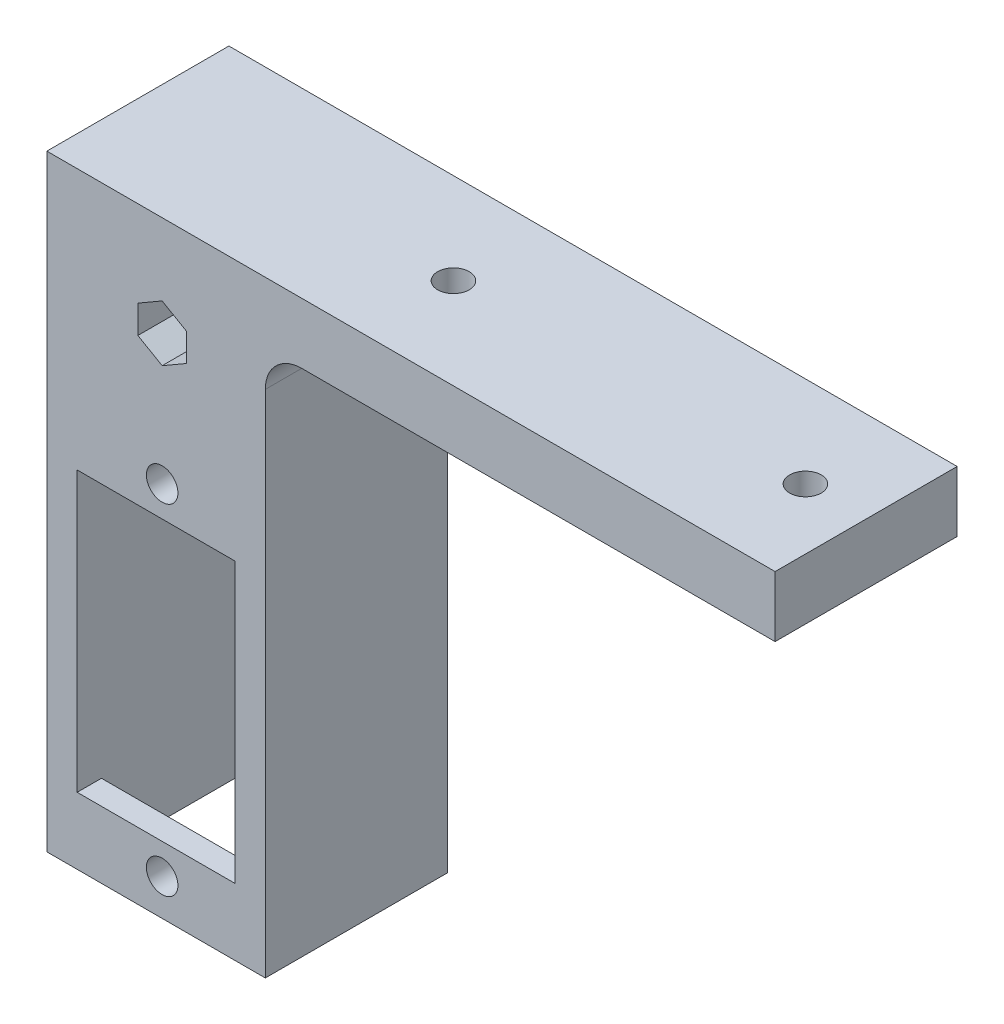
from build123d import *

# Parameters (mm, degrees)
DODANIE_WYCI_GNI_CIE1_DEPTH = 15
OTW_R_POD_RUB_M21_D         = 2.6
OTW_R_POD_RUB_M21_DEPTH     = 5
SZKIC7_W                    = 13
SZKIC7_H                    = 34
WYTNIJ_WYCI_GNI_CIE2_DEPTH  = 13
WYTNIJ_WYCI_GNI_CIE3_REACH  = 4
SZKIC8_W                    = 13
SZKIC8_H                    = 23
OTW_R_POD_RUB_M22_D         = 2.6
OTW_R_POD_RUB_M22_DEPTH     = 2
SZKIC13_R                   = 3.3
DODANIE_WYCI_GNI_CIE2_DEPTH = 4
WYTNIJ_WYCI_GNI_CIE4_REACH  = 21
SZKIC11_R                   = 1.3
WYTNIJ_WYCI_GNI_CIE5_DEPTH  = 10
ZAOKR_GLENIE1_R             = 3


with BuildPart() as part:
    # Szkic1 → Dodanie-wyciągnięcie1 (new body)
    with BuildSketch(Plane.XY):
        Polygon((-30, -2.5), (-30, 2.5), (30, 2.5), (30, -2.5), (-12, -2.5), (-12, -47.5), (-30, -47.5), align=None)
    extrude(amount=DODANIE_WYCI_GNI_CIE1_DEPTH)

    # Otwór pod śrubę M21
    with Locations(Plane(origin=(0, 2.5, 0), x_dir=(-1, 0, 0), z_dir=(0, 1, 0))):
        with Locations((-25, 7.5), (4, 7.5)):
            Hole(OTW_R_POD_RUB_M21_D / 2, depth=OTW_R_POD_RUB_M21_DEPTH)

    # Szkic7 → Wytnij-wyciągnięcie2 (cut)
    with BuildSketch(Plane(origin=(0, 0, 0), x_dir=(-1, 0, 0), z_dir=(0, 0, -1))):
        with Locations((21, -30.5)):
            Rectangle(SZKIC7_W, SZKIC7_H)
    extrude(amount=-WYTNIJ_WYCI_GNI_CIE2_DEPTH, mode=Mode.SUBTRACT)

    # Szkic8 → Wytnij-wyciągnięcie3 (cut, up to next)
    with BuildSketch(Plane(origin=(0, 0, 13), x_dir=(-1, 0, 0), z_dir=(0, 0, -1)), mode=Mode.PRIVATE) as wytnij_wyci_gni_cie3_sk1:
        with Locations((21, -30.5)):
            Rectangle(SZKIC8_W, SZKIC8_H)
    wytnij_wyci_gni_cie3_tool1 = extrude(wytnij_wyci_gni_cie3_sk1.sketch, amount=-WYTNIJ_WYCI_GNI_CIE3_REACH, mode=Mode.PRIVATE) & part.part
    add(wytnij_wyci_gni_cie3_tool1.solids().sort_by_distance((-21, -30.5, 13))[0], mode=Mode.SUBTRACT)

    # Otwór pod śrubę M22
    with Locations(Plane(origin=(0, 0, 13), x_dir=(-1, 0, 0), z_dir=(0, 0, -1))):
        with Locations((20.5, -16.5), (20.5, -44.5)):
            Hole(OTW_R_POD_RUB_M22_D / 2, depth=OTW_R_POD_RUB_M22_DEPTH)

    # Szkic13 → Dodanie-wyciągnięcie2 (add)
    with BuildSketch(Plane(origin=(0, 0, 0), x_dir=(-1, 0, 0), z_dir=(0, 0, -1))):
        with Locations((20.5, -5.75)):
            Circle(SZKIC13_R)
    extrude(amount=DODANIE_WYCI_GNI_CIE2_DEPTH)

    # Szkic11 → Wytnij-wyciągnięcie4 (cut, up to next)
    with BuildSketch(Plane(origin=(0, 0, -4), x_dir=(-1, 0, 0), z_dir=(0, 0, -1)), mode=Mode.PRIVATE) as wytnij_wyci_gni_cie4_sk1:
        with Locations((20.5, -5.75)):
            Circle(SZKIC11_R)
    wytnij_wyci_gni_cie4_tool1 = extrude(wytnij_wyci_gni_cie4_sk1.sketch, amount=-WYTNIJ_WYCI_GNI_CIE4_REACH, mode=Mode.PRIVATE) & part.part
    add(wytnij_wyci_gni_cie4_tool1.solids().sort_by_distance((-20.5, -5.75, -4))[0], mode=Mode.SUBTRACT)

    # Szkic12 → Wytnij-wyciągnięcie5 (cut)
    with BuildSketch(Plane.XY.offset(15)):
        Polygon((-18.5, -6.904700538), (-18.5, -4.595299462), (-20.5, -3.440598923), (-22.5, -4.595299462), (-22.5, -6.904700538), (-20.5, -8.059401077), align=None)
    extrude(amount=-WYTNIJ_WYCI_GNI_CIE5_DEPTH, mode=Mode.SUBTRACT)

    # Zaokrąglenie1
    zaokr_glenie1_edges = [part.edges().sort_by_distance(p)[0] for p in [
        (-12, -2.5, 7.5),
    ]]
    fillet(zaokr_glenie1_edges, radius=ZAOKR_GLENIE1_R)


solid = part.part
